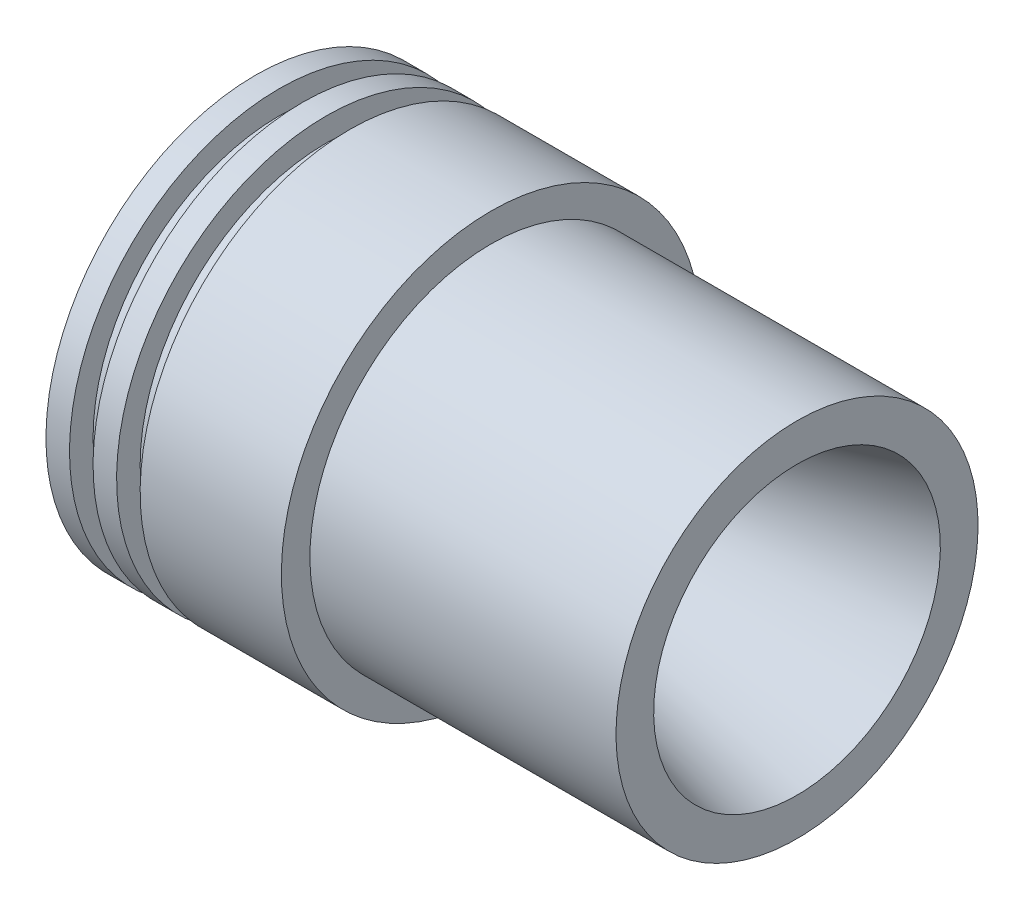
from build123d import *


with BuildPart() as part:
    # Sketch1 → Revolve1 (revolve)
    with BuildSketch(Plane.XY):
        Polygon((-115, 36.5), (-71.698729811, 11.5), (-70.698729811, 11.5), (0, 30.443667559), (0, 38.443667559), (-65, 38.443667559), (-65, 44.5), (-95, 44.5), (-95, 39.5), (-100, 39.5), (-100, 44.5), (-105, 44.5), (-105, 39.5), (-110, 39.5), (-110, 44.5), (-115, 44.5), align=None)
    revolve(axis=Axis((0, 0, 0), (-1, 0, 0)))


solid = part.part
